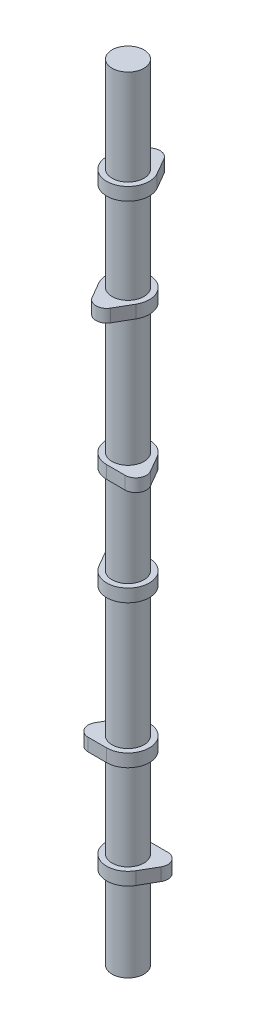
from build123d import *

# Parameters (mm, degrees)
BOSS_EXTRUDE1_DEPTH      = 3.81
LPATTERN1_COUNT          = 2
LPATTERN1_PITCH          = 61
BODY_MOVE_COPY1_ANGLE    = 180
LPATTERN2_COUNT          = 3
LPATTERN2_PITCH          = 146.05
BODY_MOVE_COPY2_ANGLE    = 120
BODY_MOVE_COPY3_ANGLE    = 120
BOSS_EXTRUDE2_DEPTH      = 1
BOSS_EXTRUDE2_DEPTH_BACK = 466.09
BOSS_EXTRUDE2_START      = 59.53
SKETCH2_R                = 9.5


with BuildPart() as part:
    # Sketch1 → Boss-Extrude1 (new, symmetric)
    with BuildSketch(Plane(origin=(0, 0, 0), x_dir=(1, 0, 0), z_dir=(0, 1, 0))):
        with BuildLine():
            Line((-5.499261314, 15.875), (-10.998522628, 6.35))
            ThreePointArc((-10.998522628, 6.35), (0, -12.7), (10.998522628, 6.35))
            Line((10.998522628, 6.35), (5.499261314, 15.875))
            ThreePointArc((5.499261314, 15.875), (0, 19.05), (-5.499261314, 15.875))
        make_face()
    extrude(amount=BOSS_EXTRUDE1_DEPTH, both=True)


with BuildPart() as lpattern1_1:
    # LPattern1: pattern copy
    add(part.part.moved(Location(Vector(0, -1, 0) * (1 * LPATTERN1_PITCH))))


with BuildPart() as lpattern1_1_1:
    # Body-Move_Copy1: moved
    add(lpattern1_1.part.rotate(Axis((0, 0, 0), (0, 1, 0)), BODY_MOVE_COPY1_ANGLE))


with BuildPart() as lpattern2_1:
    # LPattern2: pattern copy
    add(part.part.moved(Location(Vector(0, -1, 0) * (1 * LPATTERN2_PITCH))))


with BuildPart() as lpattern2_2:
    # LPattern2: pattern copy
    add(part.part.moved(Location(Vector(0, -1, 0) * (2 * LPATTERN2_PITCH))))


with BuildPart() as lpattern2_3:
    # LPattern2: pattern copy
    add(lpattern1_1_1.part.moved(Location(Vector(0, -1, 0) * (1 * LPATTERN2_PITCH))))


with BuildPart() as lpattern2_4:
    # LPattern2: pattern copy
    add(lpattern1_1_1.part.moved(Location(Vector(0, -1, 0) * (2 * LPATTERN2_PITCH))))


with BuildPart() as lpattern2_1_1:
    # Body-Move_Copy2: moved
    add(lpattern2_1.part.rotate(Axis((0, 0, 0), (0, -1, 0)), BODY_MOVE_COPY2_ANGLE))


with BuildPart() as lpattern2_3_1:
    # Body-Move_Copy2: moved
    add(lpattern2_3.part.rotate(Axis((0, 0, 0), (0, -1, 0)), BODY_MOVE_COPY2_ANGLE))


with BuildPart() as lpattern2_2_1:
    # Body-Move_Copy3: moved
    add(lpattern2_2.part.rotate(Axis((0, 0, 0), (0, 1, 0)), BODY_MOVE_COPY3_ANGLE))


with BuildPart() as lpattern2_4_1:
    # Body-Move_Copy3: moved
    add(lpattern2_4.part.rotate(Axis((0, 0, 0), (0, 1, 0)), BODY_MOVE_COPY3_ANGLE))


with BuildPart() as part_1:
    add(part.part)

    add(lpattern1_1_1.part)  # Boss-Extrude2 merges LPattern1_1

    add(lpattern2_1_1.part)  # Boss-Extrude2 merges LPattern2_1

    add(lpattern2_2_1.part)  # Boss-Extrude2 merges LPattern2_2

    add(lpattern2_3_1.part)  # Boss-Extrude2 merges LPattern2_3

    add(lpattern2_4_1.part)  # Boss-Extrude2 merges LPattern2_4
    # Sketch2 → Boss-Extrude2 (add, two sides: drawn at the far end of the back side and taken through both)
    with BuildSketch(Plane(origin=(0, 0, 0), x_dir=(1, 0, 0), z_dir=(0, 1, 0)).offset(BOSS_EXTRUDE2_START - BOSS_EXTRUDE2_DEPTH_BACK)):
        Circle(SKETCH2_R)
    extrude(amount=BOSS_EXTRUDE2_DEPTH + BOSS_EXTRUDE2_DEPTH_BACK)


solid = part_1.part
